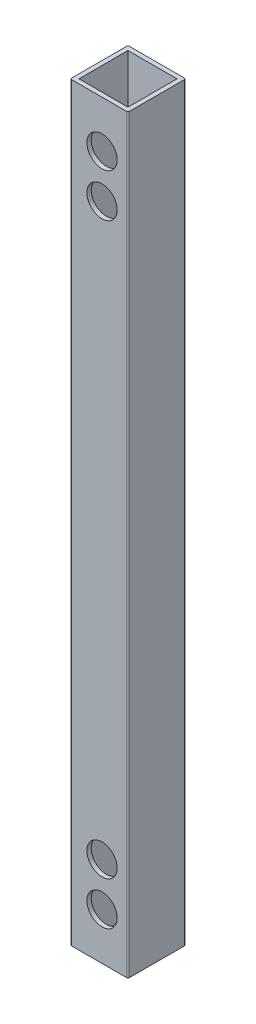
from build123d import *

# Parameters (mm, degrees)
SKETCH1_W           = 17
SKETCH1_H           = 17
BOSS_EXTRUDE1_DEPTH = 260
SKETCH2_R           = 2.65
CUT_EXTRUDE1_DEPTH  = 262.533936612
SKETCH3_R           = 5.25
CUT_EXTRUDE2_DEPTH  = 10


with BuildPart() as part:
    # Sketch1 → Boss-Extrude1 (new body)
    with BuildSketch(Plane(origin=(0, 0, 0), x_dir=(1, 0, 0), z_dir=(0, 1, 0))):
        with BuildLine():
            Line((0.5, 0), (19.5, 0))
            ThreePointArc((19.5, 0), (19.853553391, 0.146446609), (20, 0.5))
            Line((20, 0.5), (20, 19.5))
            ThreePointArc((20, 19.5), (19.853553391, 19.853553391), (19.5, 20))
            Line((19.5, 20), (0.5, 20))
            ThreePointArc((0.5, 20), (0.146446609, 19.853553391), (0, 19.5))
            Line((0, 19.5), (0, 0.5))
            ThreePointArc((0, 0.5), (0.146446609, 0.146446609), (0.5, 0))
        make_face()
        with Locations((10, 10)):
            Rectangle(SKETCH1_W, SKETCH1_H, mode=Mode.SUBTRACT)
    extrude(amount=BOSS_EXTRUDE1_DEPTH)

    # Sketch2 → Cut-Extrude1 (cut, through all)
    with BuildSketch(Plane.XY):
        with Locations((11, 243.75)):
            Circle(SKETCH2_R)
        with Locations((11, 228.75)):
            Circle(SKETCH2_R)
        with Locations((11, 31.25)):
            Circle(SKETCH2_R)
        with Locations((11, 16.25)):
            Circle(SKETCH2_R)
    extrude(amount=-CUT_EXTRUDE1_DEPTH, mode=Mode.SUBTRACT)

    # Sketch3 → Cut-Extrude2 (cut)
    with BuildSketch(Plane.XY):
        with Locations((11, 243.75)):
            Circle(SKETCH3_R)
        with Locations((11, 228.75)):
            Circle(SKETCH3_R)
        with Locations((11, 31.25)):
            Circle(SKETCH3_R)
        with Locations((11, 16.25)):
            Circle(SKETCH3_R)
    extrude(amount=-CUT_EXTRUDE2_DEPTH, mode=Mode.SUBTRACT)


solid = part.part
